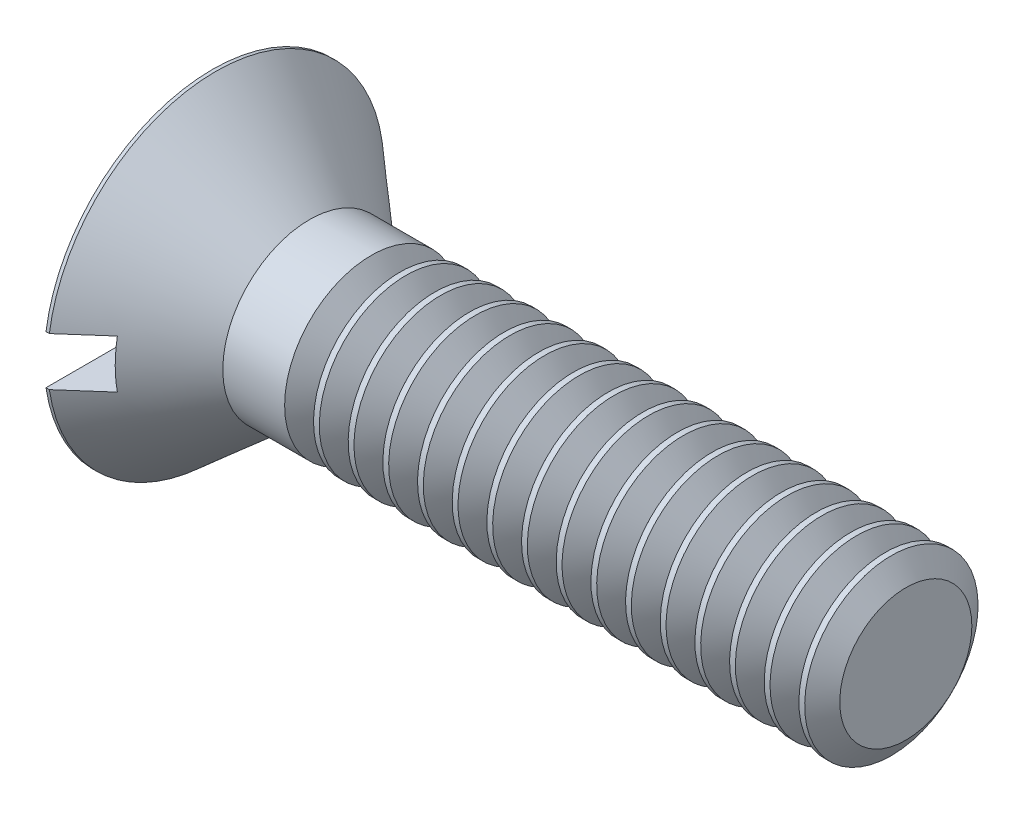
from build123d import *

# Parameters (mm, degrees)
SKETCH6_W       = 12.319
SKETCH6_H       = 1.778
SLOT_DEPTH      = 1.4478
THDSCHPAT_COUNT = 16
THDSCHPAT_PITCH = 1.27


with BuildPart() as part:
    # BodySke → Base-Revolve (revolve)
    with BuildSketch(Plane.XY):
        Polygon((0, 0), (0, 6.1595), (0.122725489, 6.1595), (3.556, 3.175), (25.4, 3.175), (25.4, 0), align=None)
    revolve(axis=Axis((-6.35, 0, 0), (1, 0, 0)))

    # Sketch6 → Slot (cut)
    with BuildSketch(Plane.ZY):
        Rectangle(SKETCH6_W, SKETCH6_H)
    extrude(amount=-SLOT_DEPTH, mode=Mode.SUBTRACT)

    # ThdSchSke → ThreadSchematic (revolve, cut)
    with BuildSketch(Plane.XY):
        Polygon((6.3500254, -2.41935), (5.820913574, -3.175), (5.820913574, -3.96875), (6.879137226, -3.96875), (6.879137226, -3.175), align=None)
    threadschematic = revolve(axis=Axis((-3.175, 0, 0), (1, 0, 0)), mode=Mode.SUBTRACT)

    # ThdSchPat: ThreadSchematic ×16
    with Locations(*[(i * THDSCHPAT_PITCH, 0, 0) for i in range(1, THDSCHPAT_COUNT)]):
        add(threadschematic, mode=Mode.SUBTRACT)


solid = part.part
